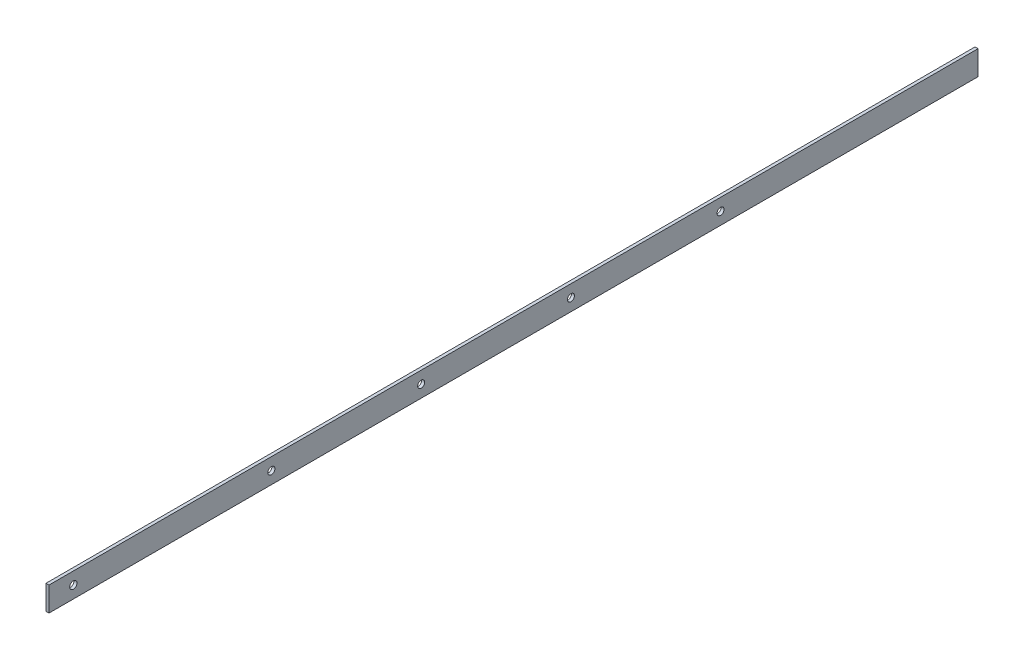
from build123d import *

# Parameters (mm, degrees)
SKETCH1_W             = 1.5875
SKETCH1_H             = 12.7
BOSS_EXTRUDE1_DEPTH   = 485.14
F_6_CLEARANCE_HOLE1_D = 3.7973
F_6_CLEARANCE_HOLE2_D = 3.6576


with BuildPart() as part:
    # Sketch1 → Boss-Extrude1 (new body)
    with BuildSketch(Plane.XY):
        with Locations((0.79375, 6.35)):
            Rectangle(SKETCH1_W, SKETCH1_H)
    extrude(amount=BOSS_EXTRUDE1_DEPTH)

    # #6 Clearance Hole1 (through all)
    with Locations(Plane(origin=(1.5875, 0, 0), x_dir=(0, 0, -1), z_dir=(1, 0, 0))):
        with Locations((-472.44, 6.35)):
            Hole(F_6_CLEARANCE_HOLE1_D / 2)

    # #6 Clearance Hole2 (through all)
    with Locations(Plane(origin=(7.14375, -24.631267391, -47.650434272), x_dir=(0, 0, -1), z_dir=(1, 0, 0))):
        with Locations((-416.683873726, 30.981267391), (-338.451873726, 30.981267391), (-260.219873726, 30.981267391), (-182.081072585, 30.981267391)):
            Hole(F_6_CLEARANCE_HOLE2_D / 2)


solid = part.part
